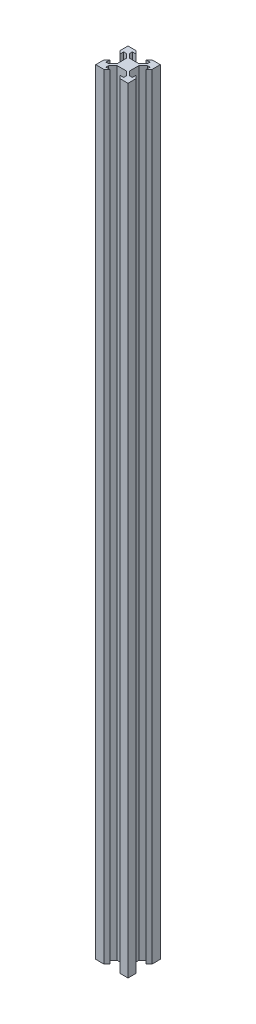
from build123d import *

# Parameters (mm, degrees)
BOSS_EXTRUDE1_DEPTH = 480


with BuildPart() as part:
    # Sketch1 → Boss-Extrude1 (new body)
    with BuildSketch(Plane(origin=(0, 0, 0), x_dir=(1, 0, 0), z_dir=(0, 1, 0))):
        Polygon((2.84, -3.900660172), (-2.84, -3.900660172), (-5.499339828, -6.56), (-5.499339828, -8.2), (-3.1, -8.2), (-4.9, -10), (-10, -10), (-10, -4.9), (-8.2, -3.1), (-8.2, -5.499339828), (-6.56, -5.499339828), (-3.900660172, -2.84), (-3.900660172, 2.84), (-6.56, 5.499339828), (-8.2, 5.499339828), (-8.2, 3.1), (-10, 4.9), (-10, 10), (-4.9, 10), (-3.1, 8.2), (-5.499339828, 8.2), (-5.499339828, 6.56), (-2.84, 3.900660172), (2.84, 3.900660172), (5.499339828, 6.56), (5.499339828, 8.2), (3.1, 8.2), (4.9, 10), (10, 10), (10, 4.9), (8.2, 3.1), (8.2, 5.499339828), (6.56, 5.499339828), (3.900660172, 2.84), (3.900660172, -2.84), (6.56, -5.499339828), (8.2, -5.499339828), (8.2, -3.1), (10, -4.9), (10, -10), (4.9, -10), (3.1, -8.2), (5.499339828, -8.2), (5.499339828, -6.56), align=None)
    extrude(amount=BOSS_EXTRUDE1_DEPTH)


solid = part.part
